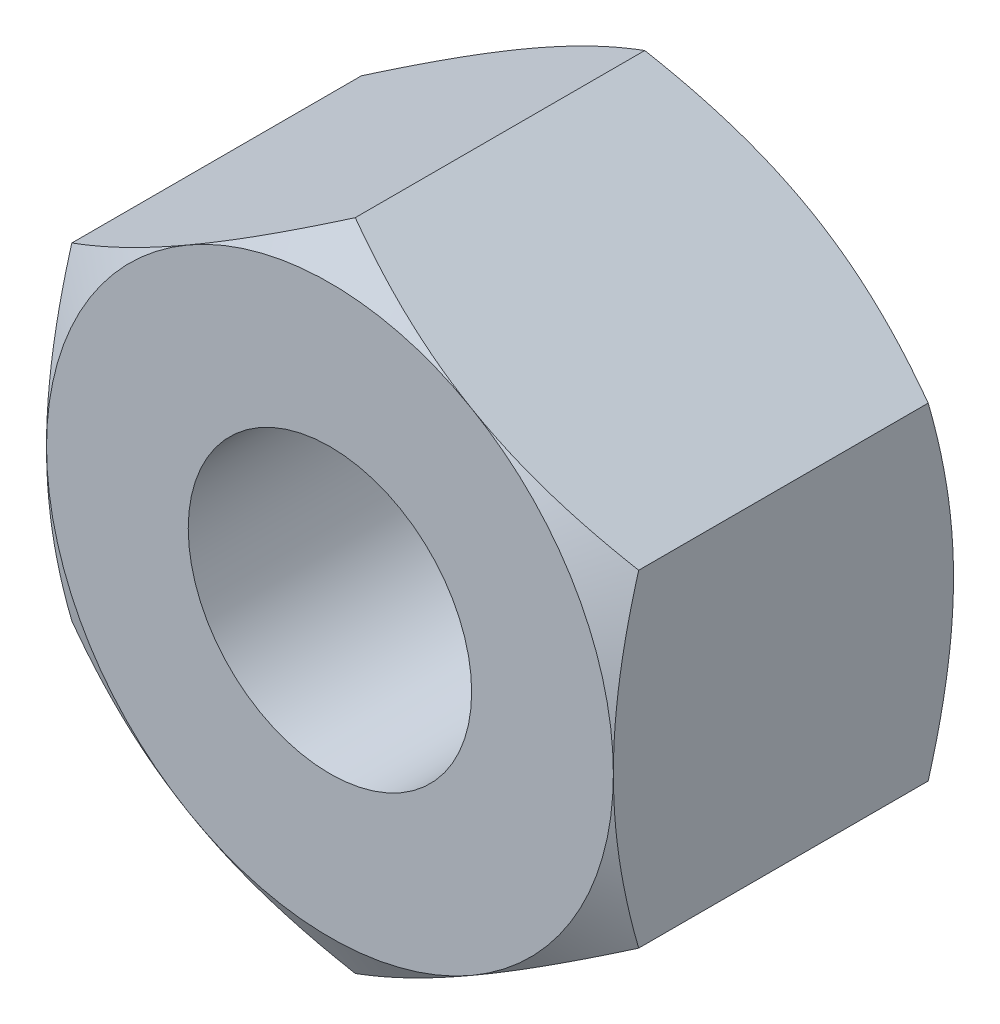
from build123d import *

# Parameters (mm, degrees)
BOSS_EXTRU_1_DEPTH      = 6
ENL_V_MAT_EXTRU_1_REACH = 8
ESQUISSE2_R             = 2.5


with BuildPart() as part:
    # Esquisse1 → Boss.-Extru.1 (new body)
    with BuildSketch(Plane.XY):
        Polygon((0, 5.773502692), (-5, 2.886751346), (-5, -2.886751346), (0, -5.773502692), (5, -2.886751346), (5, 2.886751346), align=None)
    extrude(amount=BOSS_EXTRU_1_DEPTH)

    # Esquisse2 → Enlèv. mat.-Extru.1 (cut, up to next)
    with BuildSketch(Plane.XY.offset(6), mode=Mode.PRIVATE) as enl_v_mat_extru_1_sk1:
        Circle(ESQUISSE2_R)
    enl_v_mat_extru_1_tool1 = extrude(enl_v_mat_extru_1_sk1.sketch, amount=-ENL_V_MAT_EXTRU_1_REACH, mode=Mode.PRIVATE) & part.part
    add(enl_v_mat_extru_1_tool1.solids().sort_by_distance((0, 0, 6))[0], mode=Mode.SUBTRACT)

    # Esquisse4 → Enlèvement de matière-Révolution8 (revolve, cut)
    with BuildSketch(Plane(origin=(0, 0, 0), x_dir=(1, 0, 0), z_dir=(0, 1, 0))):
        Polygon((-10.196152423, -3), (-3.267949192, 1), (-11.196152423, 1), (-11.196152423, -7), (-3.267949192, -7), align=None)
    revolve(axis=Axis((0, 0, 0), (0, 0, 1)), mode=Mode.SUBTRACT)


solid = part.part
